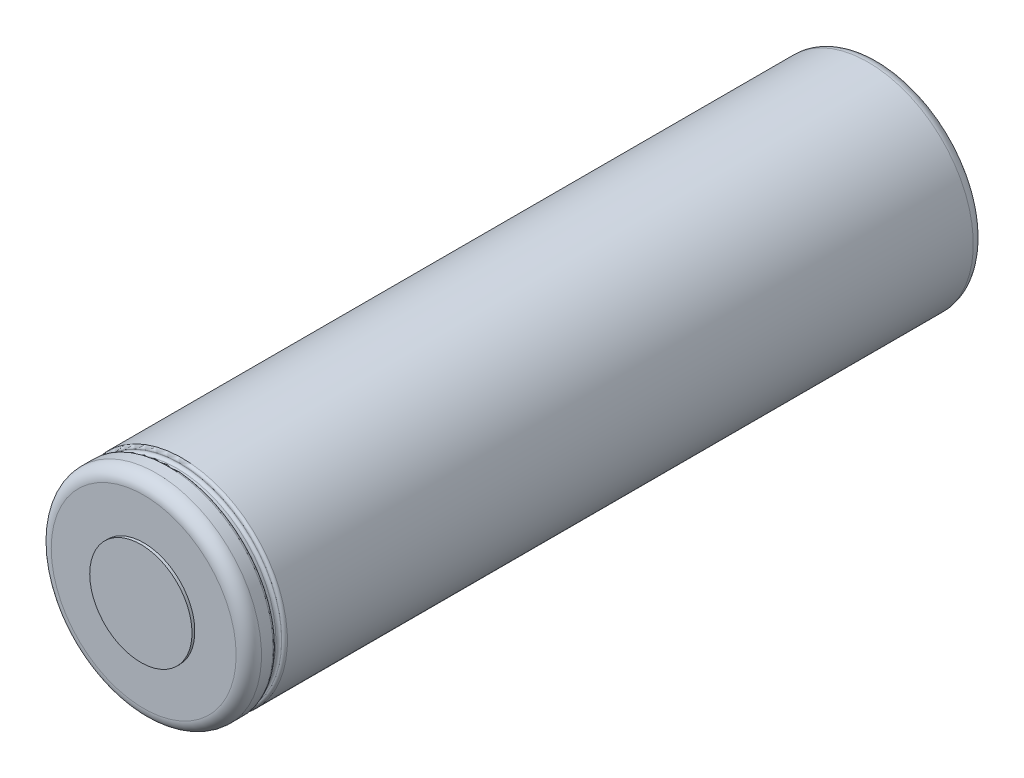
from build123d import *


with BuildPart() as part:
    # Sketch2 → Revolve1 (revolve)
    with BuildSketch(Plane(origin=(0, 0, 0), x_dir=(0, 0, -1), z_dir=(1, 0, 0))):
        with BuildLine():
            Line((0, 0), (-65, 0))
            Line((-65, 0), (-65, 4.5))
            Line((-65, 4.5), (-64.75, 4.5))
            Line((-64.75, 4.5), (-64.75, 8.136103695))
            ThreePointArc((-64.75, 8.136103695), (-64.423747326, 8.923747326), (-63.636103695, 9.25))
            Line((-63.636103695, 9.25), (-62.605654255, 9.25))
            ThreePointArc((-62.605654255, 9.25), (-62.42887756, 9.176776695), (-62.355654255, 9))
            Line((-62.355654255, 9), (-62.355654255, 8.989708105))
            ThreePointArc((-62.355654255, 8.989708105), (-62.28243095, 8.812931409), (-62.105654255, 8.739708105))
            Line((-62.105654255, 8.739708105), (-61.853839547, 8.739708105))
            ThreePointArc((-61.853839547, 8.739708105), (-61.677062851, 8.812931409), (-61.603839547, 8.989708105))
            Line((-61.603839547, 8.989708105), (-61.603839547, 9))
            ThreePointArc((-61.603839547, 9), (-61.530616242, 9.176776695), (-61.353839547, 9.25))
            Line((-61.353839547, 9.25), (-1, 9.25))
            ThreePointArc((-1, 9.25), (-0.292893219, 8.957106781), (0, 8.25))
            Line((0, 8.25), (0, 0))
        make_face()
    revolve(axis=Axis((0, 0, 0), (0, 0, 1)))


solid = part.part
